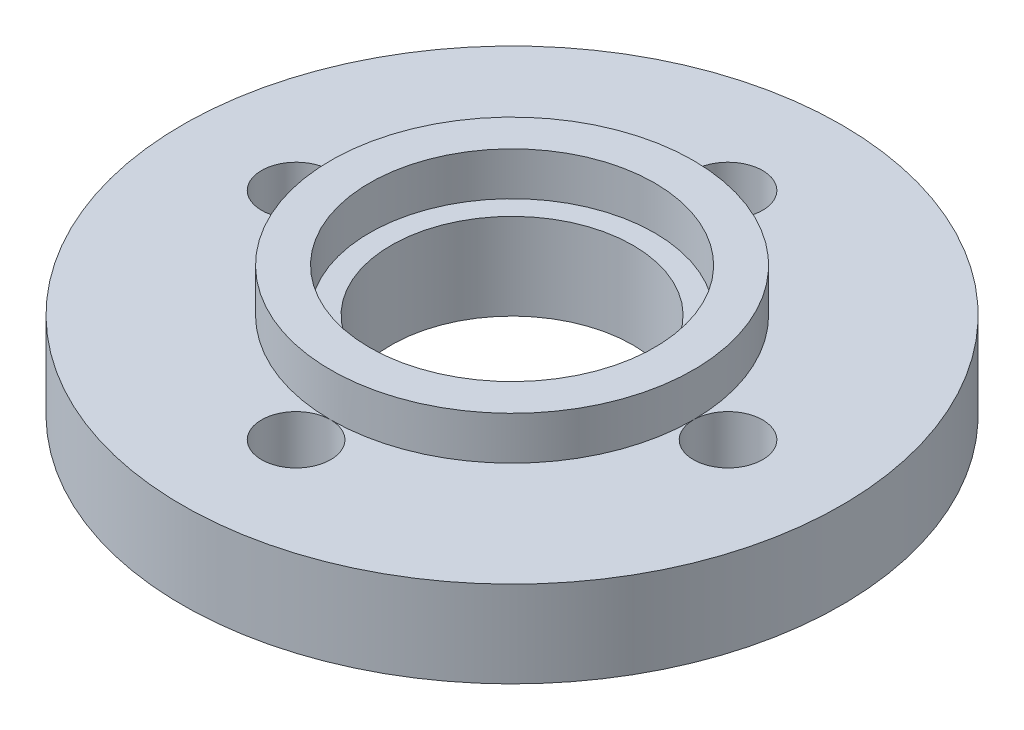
from build123d import *

# Parameters (mm, degrees)
SKETCH14_R         = 4
CUT_EXTRUDE2_DEPTH = 10


with BuildPart() as part:
    # Sketch1 → Revolve2 (revolve)
    with BuildSketch(Plane.XY):
        Polygon((14, 0.233571738), (38.150093927, 0.233571738), (38.150093927, 10.233571738), (21, 10.233571738), (21, 15.233571738), (16.5, 15.233571738), (16.5, 10.233571738), (14, 10.233571738), align=None)
    revolve(axis=Axis((0, 0, 0), (0, 1, 0)))

    # Sketch14 → Cut-Extrude2 (cut)
    with BuildSketch(Plane(origin=(0, 10.233571738, 0), x_dir=(1, 0, 0), z_dir=(0, 1, 0))):
        with Locations((25, 0)):
            Circle(SKETCH14_R)
        with Locations((0, 25)):
            Circle(SKETCH14_R)
        with Locations((-25, 0)):
            Circle(SKETCH14_R)
        with Locations((0, -25)):
            Circle(SKETCH14_R)
    extrude(amount=-CUT_EXTRUDE2_DEPTH, mode=Mode.SUBTRACT)


solid = part.part
